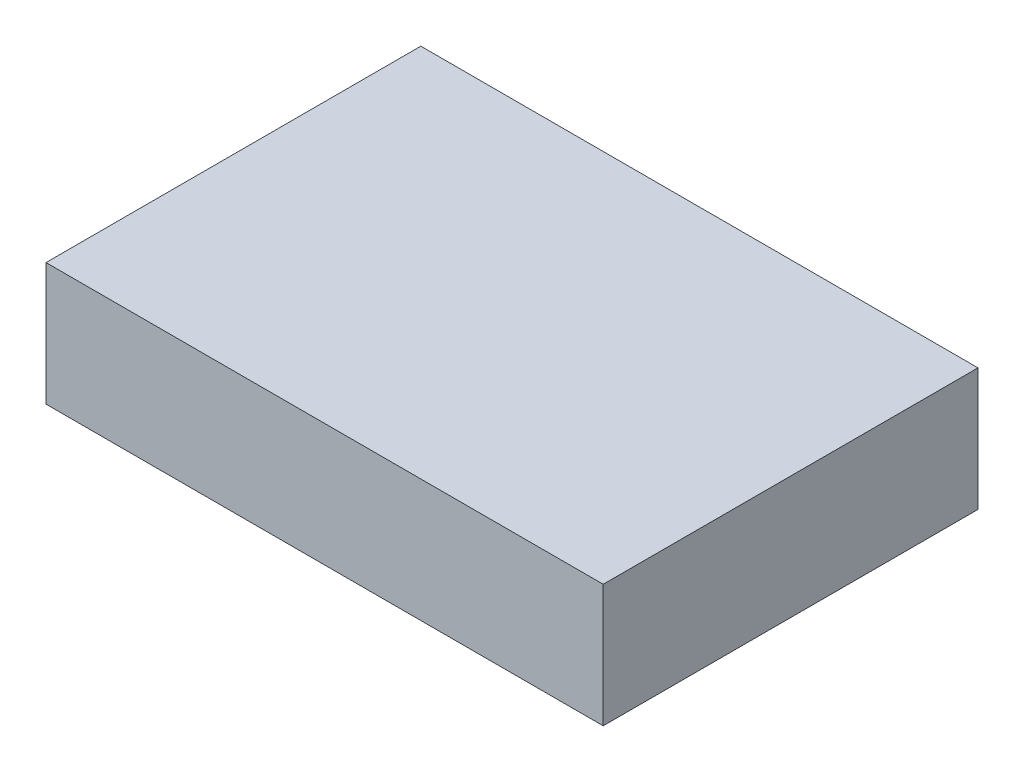
from build123d import *

# Parameters (mm, degrees)
SKETCH1_W           = 127.7
SKETCH1_H           = 85.9
BOSS_EXTRUDE1_DEPTH = 28.1


with BuildPart() as part:
    # Sketch1 → Boss-Extrude1 (new body)
    with BuildSketch(Plane(origin=(0, 0, 0), x_dir=(1, 0, 0), z_dir=(0, 1, 0))):
        with Locations((-248.856003869, 89.066665881)):
            Rectangle(SKETCH1_W, SKETCH1_H)
    extrude(amount=BOSS_EXTRUDE1_DEPTH)


solid = part.part
